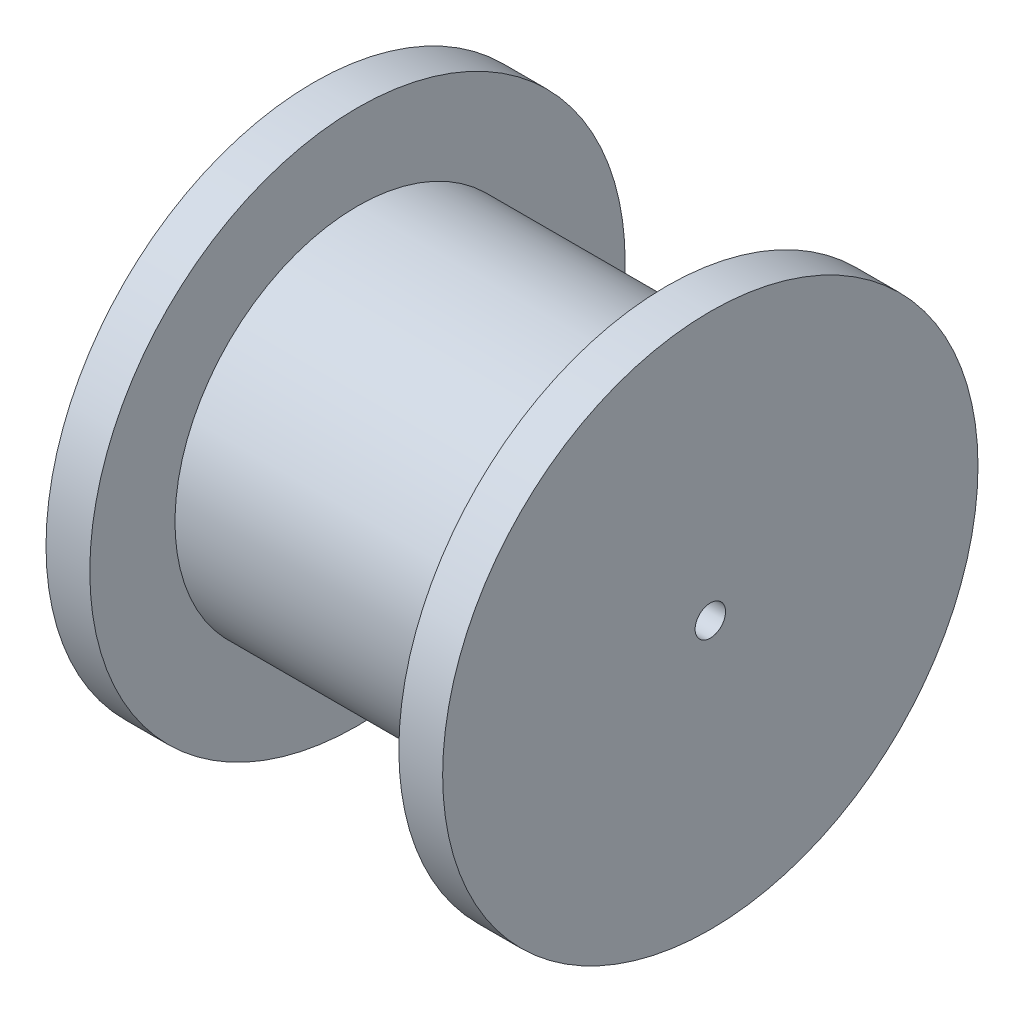
from build123d import *

# Parameters (mm, degrees)
SKETCH1_W          = 32.6
SKETCH1_H          = 15
SKETCH1_W_2        = 3.6
SKETCH1_H_2        = 7
SKETCH2_R          = 1.25
CUT_EXTRUDE1_DEPTH = 33.6


with BuildPart() as part:
    # Sketch1 → Revolve1 (revolve)
    with BuildSketch(Plane.XY):
        with Locations((-16.3, 7.5)):
            Rectangle(SKETCH1_W, SKETCH1_H)
        with Locations((-30.8, 18.5)):
            Rectangle(SKETCH1_W_2, SKETCH1_H_2)
        with Locations((-1.8, 18.5)):
            Rectangle(SKETCH1_W_2, SKETCH1_H_2)
    revolve(axis=Axis((0, 0, 0), (-1, 0, 0)))

    # Sketch2 → Cut-Extrude1 (cut, through all)
    with BuildSketch(Plane.ZY.offset(32.6)):
        Circle(SKETCH2_R)
    extrude(amount=-CUT_EXTRUDE1_DEPTH, mode=Mode.SUBTRACT)


solid = part.part
